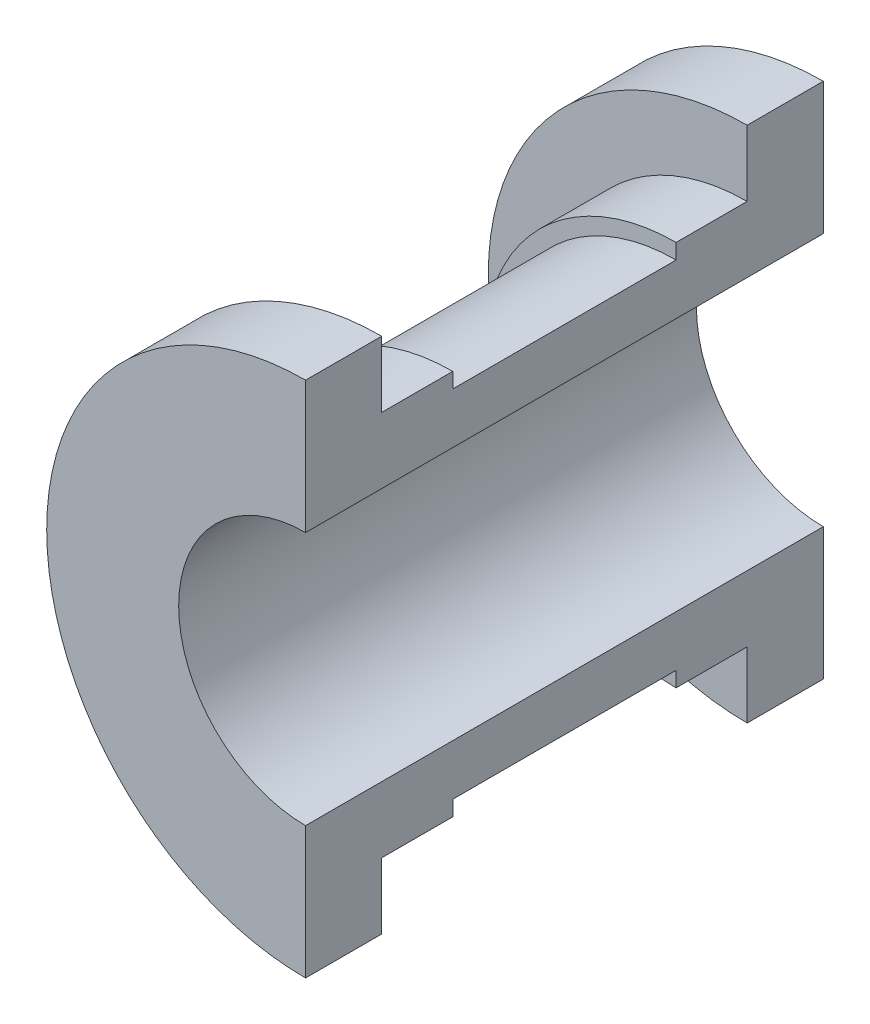
from build123d import *

# Parameters (mm, degrees)
REVOLVE1_ANGLE      = 180
SKETCH2_R           = 3
BOSS_EXTRUDE1_DEPTH = 6


with BuildPart() as part:
    # Sketch1 → Revolve1 (revolve, symmetric)
    with BuildSketch(Plane(origin=(0, 0, 0), x_dir=(1, 0, 0), z_dir=(0, 1, 0))) as revolve1_sk:
        Polygon((-12.5, 0), (-12.5, -51), (-25.5, -51), (-25.5, -43.5), (-19, -43.5), (-19, -36.5), (-17.5, -36.5), (-17.5, -14.5), (-19, -14.5), (-19, -7.5), (-25.5, -7.5), (-25.5, 0), align=None)
    revolve(axis=Axis((0, 0, -45.656895706), (0, 0, 1)), revolution_arc=REVOLVE1_ANGLE / 2)
    revolve(revolve1_sk.sketch, axis=Axis((0, 0, -45.656895706), (0, 0, -1)), revolution_arc=REVOLVE1_ANGLE / 2)


with BuildPart() as body_2:
    # Sketch2 → Boss-Extrude1 (new body)
    with BuildSketch(Plane(origin=(-17.5, 0, 0), x_dir=(0, 0, -1), z_dir=(1, 0, 0))):
        with Locations((-25.5, 0)):
            Circle(SKETCH2_R)
    extrude(amount=-BOSS_EXTRUDE1_DEPTH)


solid = Compound([part.part, body_2.part])
